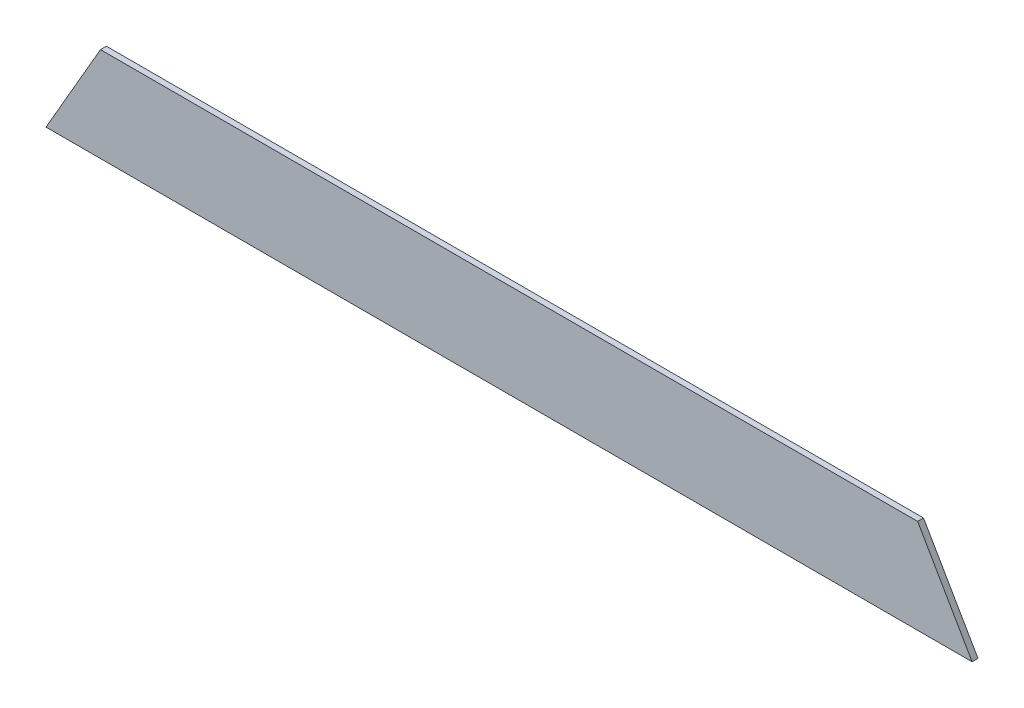
from build123d import *

# Parameters (mm, degrees)
SKETCH1_W           = 439.9534
SKETCH1_H           = 50.8
BOSS_EXTRUDE1_DEPTH = 3.175
BOSS_EXTRUDE2_DEPTH = 3.175


with BuildPart() as part:
    # Sketch1 → Boss-Extrude1 (new body)
    with BuildSketch(Plane.XY):
        with Locations((219.9767, 25.4)):
            Rectangle(SKETCH1_W, SKETCH1_H)
    extrude(amount=BOSS_EXTRUDE1_DEPTH)

    # Sketch2 → Boss-Extrude2 (add)
    with BuildSketch(Plane.XY.offset(3.175)):
        Polygon((0, 50.8), (-29.329393675, 0), (0, 0), align=None)
        Polygon((469.282793675, 0), (439.9534, 0), (439.9534, 50.8), align=None)
    extrude(amount=-BOSS_EXTRUDE2_DEPTH)


solid = part.part
